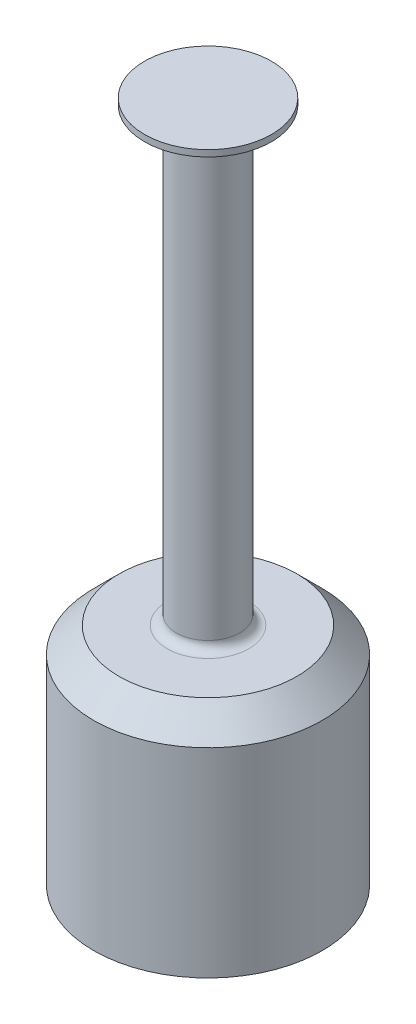
from build123d import *

# Parameters (mm, degrees)
SKETCH1_W                      = 4.5
SKETCH1_H                      = 8.85
F_5_2_5_2_DIAMETER_HOLE1_D     = 5.2
F_5_2_5_2_DIAMETER_HOLE1_DEPTH = 8.35
BOSS_EXTRUDE1_DEPTH            = 5.98
BOSS_EXTRUDE2_DEPTH            = 5.98
SKETCH6_R                      = 1.25
BOSS_EXTRUDE3_DEPTH            = 16.852002855
SKETCH7_R                      = 1.25
BOSS_EXTRUDE4_DEPTH            = 0.877097074
BOSS_EXTRUDE4_TAPER            = -54.943518707
SKETCH8_R                      = 2.5
BOSS_EXTRUDE5_DEPTH            = 0.25
CHAMFER1_SIZE                  = 1
FILLET1_R                      = 0.36


with BuildPart() as part:
    # Sketch1 → Revolve1 (revolve)
    with BuildSketch(Plane.XY):
        with Locations((2.25, 4.575)):
            Rectangle(SKETCH1_W, SKETCH1_H)
    revolve(axis=Axis((0, 9, 0), (0, -1, 0)))

    # Ø5.2 (5.2) Diameter Hole1
    with Locations(Plane(origin=(0, 0.15, 0), x_dir=(-1, 0, 0), z_dir=(0, -1, 0))):
        with Locations((0, 0)):
            Hole(F_5_2_5_2_DIAMETER_HOLE1_D / 2, depth=F_5_2_5_2_DIAMETER_HOLE1_DEPTH)

    # Sketch4 → Boss-Extrude1 (add)
    with BuildSketch(Plane.XZ.offset(-8.5)):
        with BuildLine():
            Line((-2, -1.661324773), (2, -1.661324773))
            ThreePointArc((2, -1.661324773), (0, -2.6), (-2, -1.661324773))
        make_face()
    extrude(amount=BOSS_EXTRUDE1_DEPTH)

    # Sketch5 → Boss-Extrude2 (add)
    with BuildSketch(Plane.XZ.offset(-8.5)):
        with BuildLine():
            Line((2, 1.661324773), (-2, 1.661324773))
            ThreePointArc((-2, 1.661324773), (0, 2.6), (2, 1.661324773))
        make_face()
    extrude(amount=BOSS_EXTRUDE2_DEPTH)

    # Sketch6 → Boss-Extrude3 (add)
    with BuildSketch(Plane(origin=(0, 9, 0), x_dir=(-1, 0, 0), z_dir=(0, 1, 0))):
        Circle(SKETCH6_R)
    extrude(amount=BOSS_EXTRUDE3_DEPTH)

    # Sketch7 → Boss-Extrude4 (add)
    with BuildSketch(Plane(origin=(0, 25.852002855, 0), x_dir=(-1, 0, 0), z_dir=(0, 1, 0))):
        Circle(SKETCH7_R)
    extrude(amount=BOSS_EXTRUDE4_DEPTH, taper=BOSS_EXTRUDE4_TAPER)

    # Sketch8 → Boss-Extrude5 (add)
    with BuildSketch(Plane(origin=(0, 26.729099929, 0), x_dir=(-1, 0, 0), z_dir=(0, 1, 0))):
        Circle(SKETCH8_R)
    extrude(amount=BOSS_EXTRUDE5_DEPTH)

    # Chamfer1
    chamfer1_edges = [part.edges().sort_by_distance(p)[0] for p in [
        (-4.5, 9, 0),
    ]]
    chamfer(chamfer1_edges, length=CHAMFER1_SIZE)

    # Fillet1
    fillet1_edges = [part.edges().sort_by_distance(p)[0] for p in [
        (1.25, 9, 0),
    ]]
    fillet(fillet1_edges, radius=FILLET1_R)


solid = part.part
